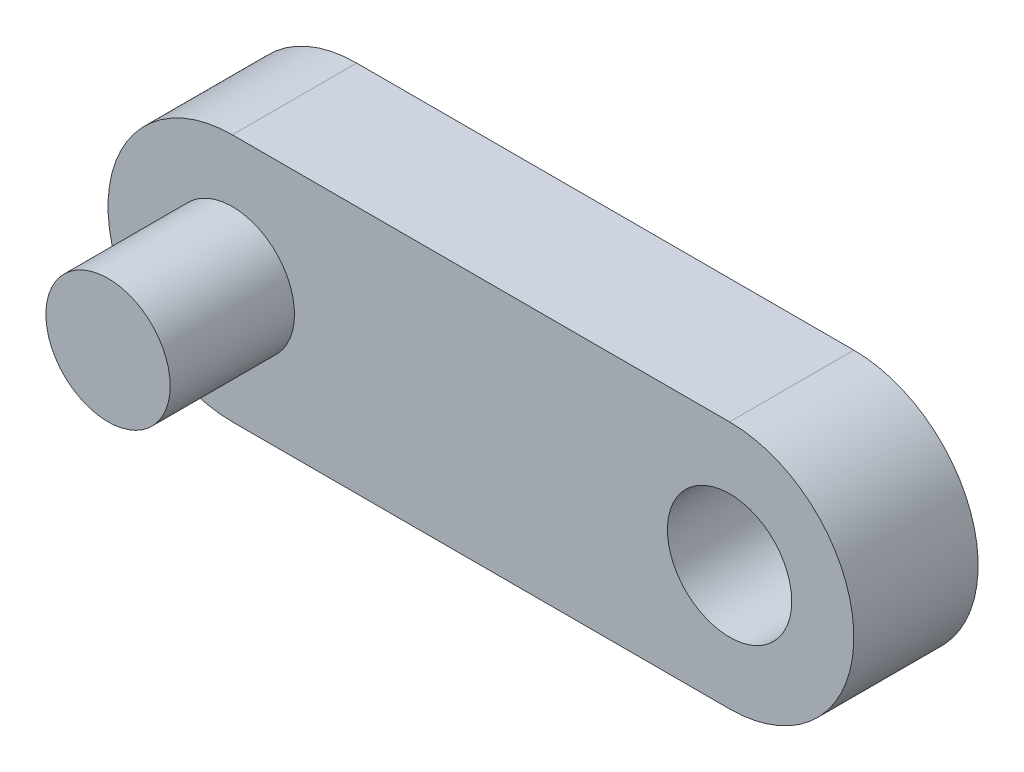
from build123d import *

# Parameters (mm, degrees)
SKETCH1_R           = 2.5
BOSS_EXTRUDE1_DEPTH = 5
SKETCH1_2_R         = 2.5
BOSS_EXTRUDE2_DEPTH = 10


with BuildPart() as part:
    # Sketch1 → Boss-Extrude1 (new body)
    with BuildSketch(Plane.XY):
        with BuildLine():
            Line((-10, 5), (10, 5))
            ThreePointArc((10, 5), (15, 0), (10, -5))
            Line((10, -5), (-10, -5))
            ThreePointArc((-10, -5), (-15, 0), (-10, 5))
        make_face()
        with Locations((-10, 0)):
            Circle(SKETCH1_R, mode=Mode.SUBTRACT)
        with Locations((10, 0)):
            Circle(SKETCH1_R, mode=Mode.SUBTRACT)
    extrude(amount=BOSS_EXTRUDE1_DEPTH)

    # Sketch1_2 → Boss-Extrude2 (add)
    with BuildSketch(Plane.XY):
        with Locations((-10, 0)):
            Circle(SKETCH1_2_R)
    extrude(amount=BOSS_EXTRUDE2_DEPTH)


solid = part.part
